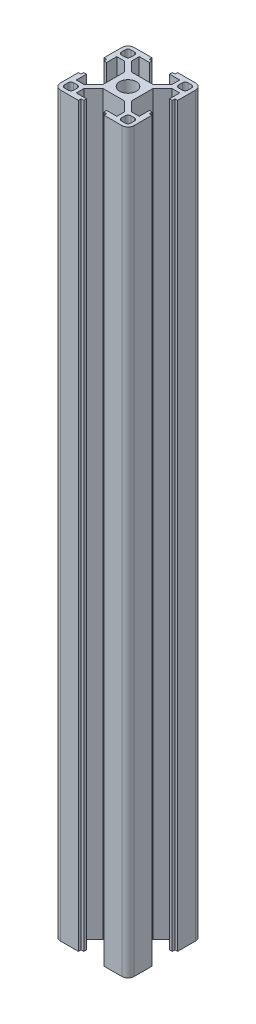
from build123d import *

# Parameters (mm, degrees)
SKETCH1_R           = 3.4
BOSS_EXTRUDE1_DEPTH = 300


with BuildPart() as part:
    # Sketch1 → Boss-Extrude1 (new body)
    with BuildSketch(Plane(origin=(0, 100, 0), x_dir=(1, 0, 0), z_dir=(0, 1, 0))):
        with BuildLine():
            Line((27.5, 0), (20.200000224, 0))
            Line((20.200000224, 0), (20.200000224, -1.1))
            Line((20.200000224, -1.1), (19.1, -1.1))
            Line((19.1, -1.1), (19.1, -2.2))
            Line((19.1, -2.2), (23.249999989, -2.2))
            Line((23.249999989, -2.2), (23.249999989, -5.335786427))
            Line((23.249999989, -5.335786427), (19.385786417, -9.2))
            Line((19.385786417, -9.2), (10.614213562, -9.2))
            Line((10.614213562, -9.2), (6.75, -5.335786438))
            Line((6.75, -5.335786438), (6.75, -2.2))
            Line((6.75, -2.2), (10.9, -2.2))
            Line((10.9, -2.2), (10.9, -1.1))
            Line((10.9, -1.1), (9.799999776, -1.1))
            Line((9.799999776, -1.1), (9.799999776, 0))
            Line((9.799999776, 0), (2.5, 0))
            ThreePointArc((2.5, 0), (0.732233047, -0.732233047), (0, -2.5))
            Line((0, -2.5), (0, -9.799999776))
            Line((0, -9.799999776), (1.1, -9.799999776))
            Line((1.1, -9.799999776), (1.1, -10.9))
            Line((1.1, -10.9), (2.199999979, -10.9))
            Line((2.199999979, -10.9), (2.199999979, -6.750000011))
            Line((2.199999979, -6.750000011), (5.335786427, -6.750000011))
            Line((5.335786427, -6.750000011), (9.199999989, -10.614213573))
            Line((9.199999989, -10.614213573), (9.199999989, -19.385786427))
            Line((9.199999989, -19.385786427), (5.335786417, -23.25))
            Line((5.335786417, -23.25), (2.199999979, -23.25))
            Line((2.199999979, -23.25), (2.199999979, -19.1))
            Line((2.199999979, -19.1), (1.1, -19.1))
            Line((1.1, -19.1), (1.1, -20.200000224))
            Line((1.1, -20.200000224), (0, -20.200000224))
            Line((0, -20.200000224), (0, -27.5))
            ThreePointArc((0, -27.5), (0.732233047, -29.267766953), (2.5, -30))
            Line((2.5, -30), (9.799999776, -30))
            Line((9.799999776, -30), (9.799999776, -28.9))
            Line((9.799999776, -28.9), (10.9, -28.9))
            Line((10.9, -28.9), (10.9, -27.8))
            Line((10.9, -27.8), (6.75, -27.8))
            Line((6.75, -27.8), (6.75, -24.664213562))
            Line((6.75, -24.664213562), (10.614213562, -20.8))
            Line((10.614213562, -20.8), (19.385786417, -20.8))
            Line((19.385786417, -20.8), (23.249999989, -24.664213573))
            Line((23.249999989, -24.664213573), (23.249999989, -27.8))
            Line((23.249999989, -27.8), (19.1, -27.8))
            Line((19.1, -27.8), (19.1, -28.9))
            Line((19.1, -28.9), (20.200000224, -28.9))
            Line((20.200000224, -28.9), (20.200000224, -30))
            Line((20.200000224, -30), (27.5, -30))
            ThreePointArc((27.5, -30), (29.267766953, -29.267766953), (30, -27.5))
            Line((30, -27.5), (30, -20.200000224))
            Line((30, -20.200000224), (28.9, -20.200000224))
            Line((28.9, -20.200000224), (28.9, -19.1))
            Line((28.9, -19.1), (27.799999979, -19.1))
            Line((27.799999979, -19.1), (27.799999979, -23.25))
            Line((27.799999979, -23.25), (24.664213562, -23.25))
            Line((24.664213562, -23.25), (20.799999989, -19.385786427))
            Line((20.799999989, -19.385786427), (20.799999989, -10.614213573))
            Line((20.799999989, -10.614213573), (24.664213552, -6.750000011))
            Line((24.664213552, -6.750000011), (27.799999979, -6.750000011))
            Line((27.799999979, -6.750000011), (27.799999979, -10.9))
            Line((27.799999979, -10.9), (28.9, -10.9))
            Line((28.9, -10.9), (28.9, -9.799999776))
            Line((28.9, -9.799999776), (30, -9.799999776))
            Line((30, -9.799999776), (30, -2.5))
            ThreePointArc((30, -2.5), (29.267766953, -0.732233047), (27.5, 0))
        make_face()
        with Locations((15, -15)):
            Circle(SKETCH1_R, mode=Mode.SUBTRACT)
        with BuildLine():
            Line((28.5, -25.9), (28.5, -27.35))
            ThreePointArc((28.5, -27.35), (28.163172798, -28.163172798), (27.35, -28.5))
            Line((27.35, -28.5), (25.9, -28.5))
            ThreePointArc((25.9, -28.5), (25.086827202, -28.163172798), (24.75, -27.35))
            Line((24.75, -27.35), (24.75, -25.9))
            ThreePointArc((24.75, -25.9), (25.086827202, -25.086827202), (25.9, -24.75))
            Line((25.9, -24.75), (27.35, -24.75))
            ThreePointArc((27.35, -24.75), (28.163172798, -25.086827202), (28.5, -25.9))
        make_face(mode=Mode.SUBTRACT)
        with BuildLine():
            Line((1.5, -27.35), (1.5, -25.9))
            ThreePointArc((1.5, -25.9), (1.836827202, -25.086827202), (2.65, -24.75))
            Line((2.65, -24.75), (4.1, -24.75))
            ThreePointArc((4.1, -24.75), (4.913172798, -25.086827202), (5.25, -25.9))
            Line((5.25, -25.9), (5.25, -27.35))
            ThreePointArc((5.25, -27.35), (4.913172798, -28.163172798), (4.1, -28.5))
            Line((4.1, -28.5), (2.65, -28.5))
            ThreePointArc((2.65, -28.5), (1.836827202, -28.163172798), (1.5, -27.35))
        make_face(mode=Mode.SUBTRACT)
        with BuildLine():
            Line((2.65, -1.5), (4.1, -1.5))
            ThreePointArc((4.1, -1.5), (4.913172798, -1.836827202), (5.25, -2.65))
            Line((5.25, -2.65), (5.25, -4.1))
            ThreePointArc((5.25, -4.1), (4.913172798, -4.913172798), (4.1, -5.25))
            Line((4.1, -5.25), (2.65, -5.25))
            ThreePointArc((2.65, -5.25), (1.836827202, -4.913172798), (1.5, -4.1))
            Line((1.5, -4.1), (1.5, -2.65))
            ThreePointArc((1.5, -2.65), (1.836827202, -1.836827202), (2.65, -1.5))
        make_face(mode=Mode.SUBTRACT)
        with BuildLine():
            Line((28.5, -2.65), (28.5, -4.1))
            ThreePointArc((28.5, -4.1), (28.163172798, -4.913172798), (27.35, -5.25))
            Line((27.35, -5.25), (25.9, -5.25))
            ThreePointArc((25.9, -5.25), (25.086827202, -4.913172798), (24.75, -4.1))
            Line((24.75, -4.1), (24.75, -2.65))
            ThreePointArc((24.75, -2.65), (25.086827202, -1.836827202), (25.9, -1.5))
            Line((25.9, -1.5), (27.35, -1.5))
            ThreePointArc((27.35, -1.5), (28.163172798, -1.836827202), (28.5, -2.65))
        make_face(mode=Mode.SUBTRACT)
    extrude(amount=-BOSS_EXTRUDE1_DEPTH)


solid = part.part
